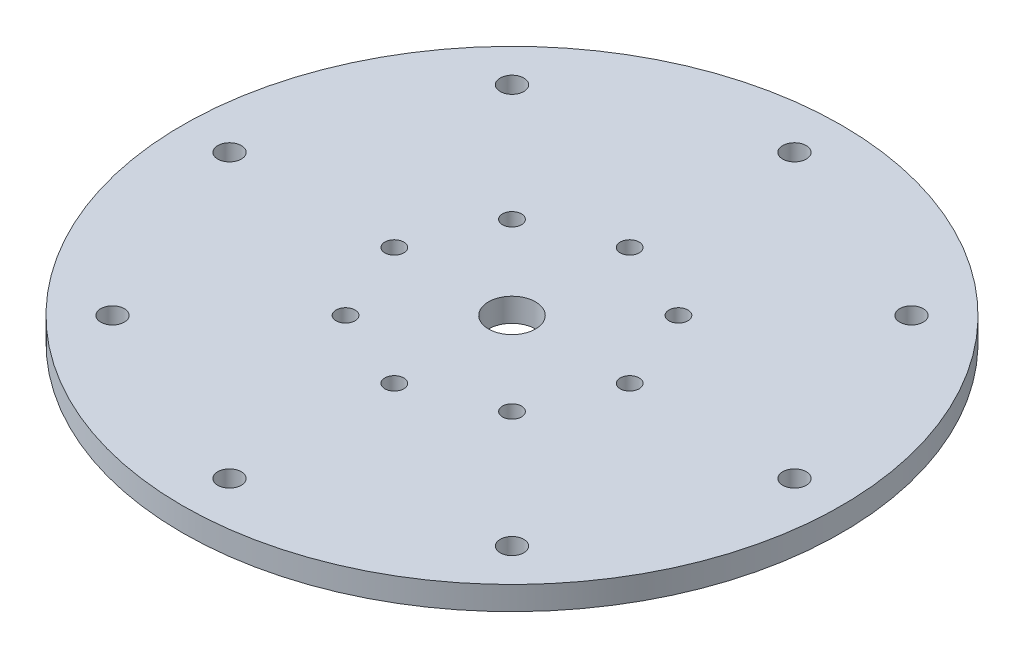
from build123d import *

# Parameters (mm, degrees)
SKETCH1_R                                          = 88.9
SKETCH1_R_2                                        = 6.35
BOSS_EXTRUDE1_DEPTH                                = 6.35
CSK_FOR_10_FLAT_HEAD_MACHINE_SCREW_100_D           = 5.1054
CSK_FOR_10_FLAT_HEAD_MACHINE_SCREW_100_CSINK_D     = 9.779
CSK_FOR_10_FLAT_HEAD_MACHINE_SCREW_100_CSINK_ANGLE = 100
F_1_4_0_25_DIAMETER_HOLE1_D                        = 6.35
CIRPATTERN1_COUNT                                  = 8


with BuildPart() as part:
    # Sketch1 → Boss-Extrude1 (new body)
    with BuildSketch(Plane(origin=(0, 0, 0), x_dir=(1, 0, 0), z_dir=(0, 1, 0))):
        Circle(SKETCH1_R)
        Circle(SKETCH1_R_2, mode=Mode.SUBTRACT)
    extrude(amount=BOSS_EXTRUDE1_DEPTH)

    # CSK for #10 Flat Head Machine Screw (100)1 (through all)
    with Locations(Plane(origin=(31.75, 0, 0), x_dir=(0, 0, -1), z_dir=(0, -1, 0))):
        with Locations((0, 0)):
            csk_for_10_flat_head_machine_screw_100 = CounterSinkHole(CSK_FOR_10_FLAT_HEAD_MACHINE_SCREW_100_D / 2, CSK_FOR_10_FLAT_HEAD_MACHINE_SCREW_100_CSINK_D / 2, counter_sink_angle=CSK_FOR_10_FLAT_HEAD_MACHINE_SCREW_100_CSINK_ANGLE)

    # 1/4 (0.25) Diameter Hole1 (through all)
    with Locations(Plane(origin=(0, 6.35, 0), x_dir=(1, 0, 0), z_dir=(0, 1, 0))):
        with Locations((76.2, 0)):
            f_1_4_0_25_diameter_hole1 = Hole(F_1_4_0_25_DIAMETER_HOLE1_D / 2)

    # CirPattern1: CSK for #10 Flat Head Machine Screw (100)1, 1/4 (0.25) Diameter Hole1 ×8 about axis
    cirpattern1_axis = Axis((0, 0, 0), (0, 1, 0))
    for i in range(1, CIRPATTERN1_COUNT):
        add(csk_for_10_flat_head_machine_screw_100.rotate(cirpattern1_axis, i * 360 / CIRPATTERN1_COUNT), mode=Mode.SUBTRACT)
        add(f_1_4_0_25_diameter_hole1.rotate(cirpattern1_axis, i * 360 / CIRPATTERN1_COUNT), mode=Mode.SUBTRACT)


solid = part.part
